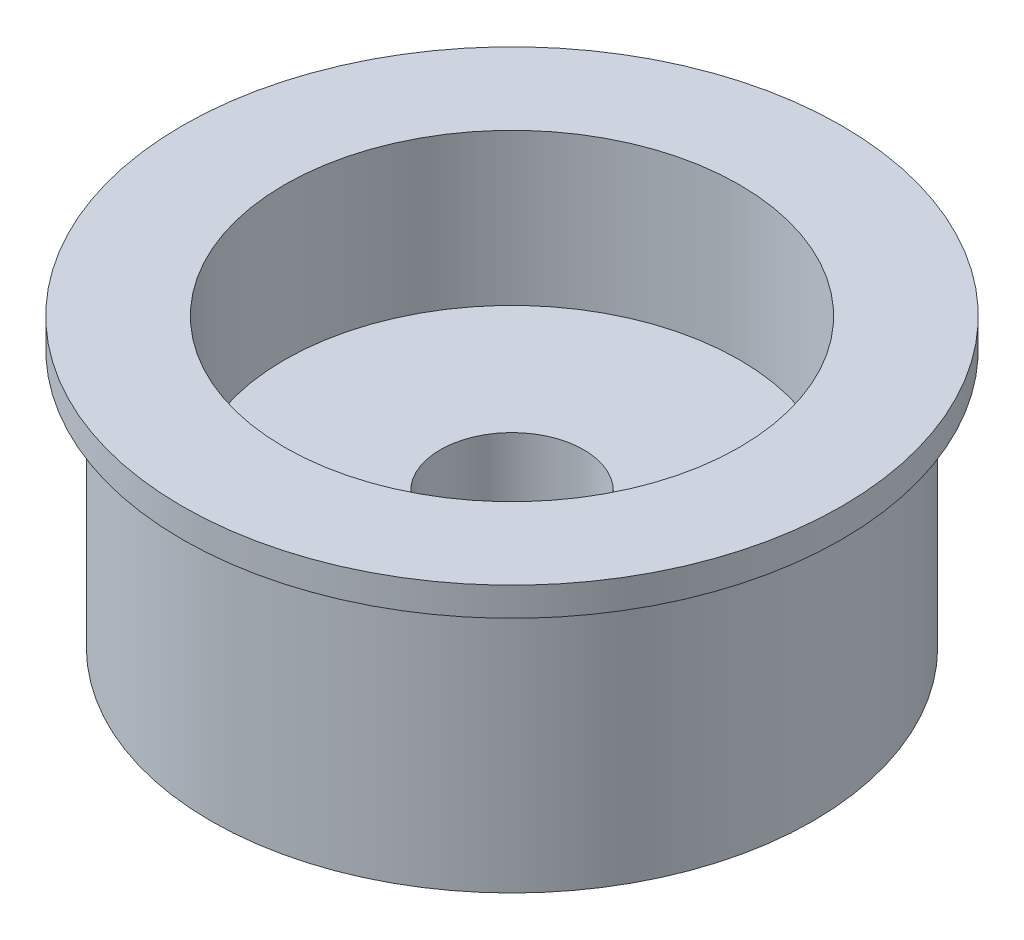
from build123d import *

# Parameters (mm, degrees)
SKETCH1_R           = 14.69
BOSS_EXTRUDE1_DEPTH = 14
SKETCH2_R           = 11.1
CUT_EXTRUDE1_DEPTH  = 7.4
SKETCH3_R           = 16.09
SKETCH3_R_2         = 14.69
BOSS_EXTRUDE2_DEPTH = 1.4
SKETCH4_R           = 3.5
CUT_EXTRUDE2_DEPTH  = 7.6


with BuildPart() as part:
    # Sketch1 → Boss-Extrude1 (new body)
    with BuildSketch(Plane(origin=(0, 0, 0), x_dir=(1, 0, 0), z_dir=(0, 1, 0))):
        Circle(SKETCH1_R)
    extrude(amount=BOSS_EXTRUDE1_DEPTH)

    # Sketch2 → Cut-Extrude1 (cut)
    with BuildSketch(Plane(origin=(0, 14, 0), x_dir=(1, 0, 0), z_dir=(0, 1, 0))):
        Circle(SKETCH2_R)
    extrude(amount=-CUT_EXTRUDE1_DEPTH, mode=Mode.SUBTRACT)

    # Sketch3 → Boss-Extrude2 (add)
    with BuildSketch(Plane(origin=(0, 14, 0), x_dir=(1, 0, 0), z_dir=(0, 1, 0))):
        Circle(SKETCH3_R)
        Circle(SKETCH3_R_2, mode=Mode.SUBTRACT)
    extrude(amount=-BOSS_EXTRUDE2_DEPTH)

    # Sketch4 → Cut-Extrude2 (cut, through all)
    with BuildSketch(Plane(origin=(0, 6.6, 0), x_dir=(1, 0, 0), z_dir=(0, 1, 0))):
        Circle(SKETCH4_R)
    extrude(amount=-CUT_EXTRUDE2_DEPTH, mode=Mode.SUBTRACT)


solid = part.part
